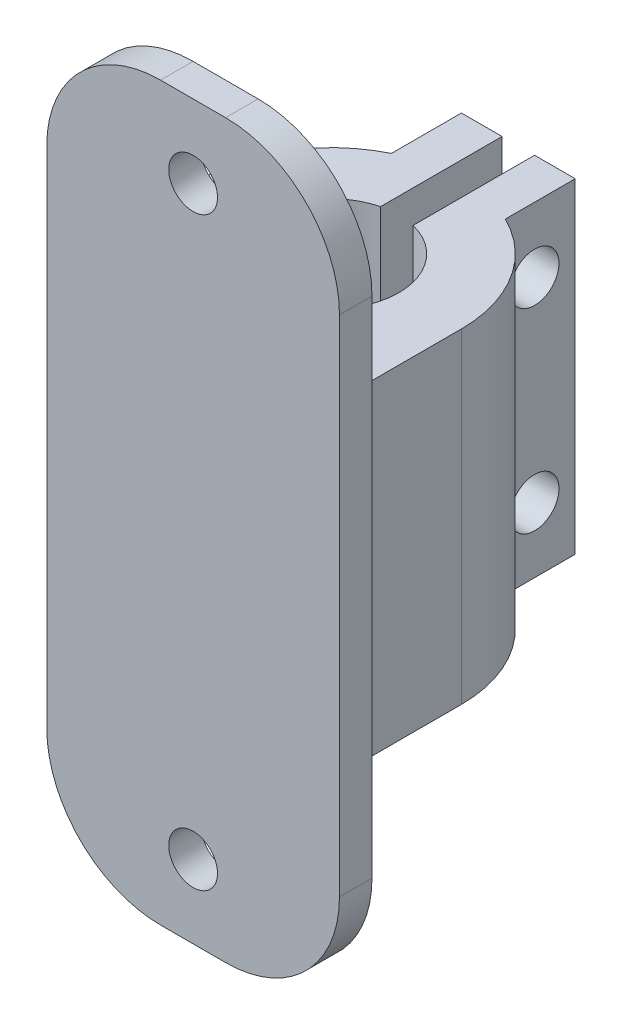
from build123d import *

# Parameters (mm, degrees)
SKETCH1_W           = 18
SKETCH1_H           = 18
BOSS_EXTRUDE1_DEPTH = 20
SKETCH2_R           = 4.15
CUT_EXTRUDE1_DEPTH  = 21
SKETCH3_R           = 1.5
CUT_EXTRUDE2_DEPTH  = 19
SKETCH4_W           = 18
SKETCH4_H           = 45
BOSS_EXTRUDE2_DEPTH = 2
SKETCH5_R           = 1.5
CUT_EXTRUDE3_DEPTH  = 21
FILLET1_R           = 7
CUT_EXTRUDE4_DEPTH  = 33.5


with BuildPart() as part:
    # Sketch1 → Boss-Extrude1 (new body)
    with BuildSketch(Plane(origin=(0, 0, 0), x_dir=(1, 0, 0), z_dir=(0, 1, 0))):
        with Locations((0, 9)):
            Rectangle(SKETCH1_W, SKETCH1_H)
    extrude(amount=BOSS_EXTRUDE1_DEPTH)

    # Sketch2 → Cut-Extrude1 (cut, through all)
    with BuildSketch(Plane(origin=(0, 20, 0), x_dir=(1, 0, 0), z_dir=(0, 1, 0))):
        with Locations((0, 6.5)):
            Circle(SKETCH2_R)
        with BuildLine():
            Line((1, 10.527716475), (1, 18))
            Line((1, 18), (0, 18))
            Line((0, 18), (-1, 18))
            Line((-1, 18), (-1, 10.527716475))
            ThreePointArc((-1, 10.527716475), (0, 2.35), (1, 10.527716475))
        make_face()
    extrude(amount=-CUT_EXTRUDE1_DEPTH, mode=Mode.SUBTRACT)

    # Sketch3 → Cut-Extrude2 (cut, through all)
    with BuildSketch(Plane(origin=(9, 0, 0), x_dir=(0, 0, -1), z_dir=(1, 0, 0))):
        with Locations((15.5, 16)):
            Circle(SKETCH3_R)
        with Locations((15.5, 4)):
            Circle(SKETCH3_R)
    extrude(amount=-CUT_EXTRUDE2_DEPTH, mode=Mode.SUBTRACT)

    # Sketch4 → Boss-Extrude2 (add)
    with BuildSketch(Plane.XY):
        with Locations((0, 10)):
            Rectangle(SKETCH4_W, SKETCH4_H)
    extrude(amount=BOSS_EXTRUDE2_DEPTH)

    # Sketch5 → Cut-Extrude3 (cut, through all)
    with BuildSketch(Plane.XY.offset(2)):
        with Locations((0, 28)):
            Circle(SKETCH5_R)
        with Locations((0, -8)):
            Circle(SKETCH5_R)
    extrude(amount=-CUT_EXTRUDE3_DEPTH, mode=Mode.SUBTRACT)

    # Fillet1
    fillet1_edges = [part.edges().sort_by_distance(p)[0] for p in [
        (9, -12.5, 1),
        (9, 32.5, 1),
        (-9, 32.5, 1),
        (-9, -12.5, 1),
    ]]
    fillet(fillet1_edges, radius=FILLET1_R)

    # Sketch6 → Cut-Extrude4 (cut, through all)
    with BuildSketch(Plane.XZ):
        with BuildLine():
            Line((-3.5, -13.693747285), (-3.5, -18))
            Line((-3.5, -18), (-9, -18))
            Line((-9, -18), (-9, 0))
            Line((-9, 0), (-8, 0))
            Line((-8, 0), (-8, -6.5))
            ThreePointArc((-8, -6.5), (-6.782329983, -10.742640687), (-3.5, -13.693747285))
        make_face()
        with BuildLine():
            Line((8, 0), (8, -6.5))
            ThreePointArc((8, -6.5), (6.782329983, -10.742640687), (3.5, -13.693747285))
            Line((3.5, -13.693747285), (3.5, -18))
            Line((3.5, -18), (9, -18))
            Line((9, -18), (9, 0))
            Line((9, 0), (8, 0))
        make_face()
    extrude(amount=-CUT_EXTRUDE4_DEPTH, mode=Mode.SUBTRACT)


solid = part.part
